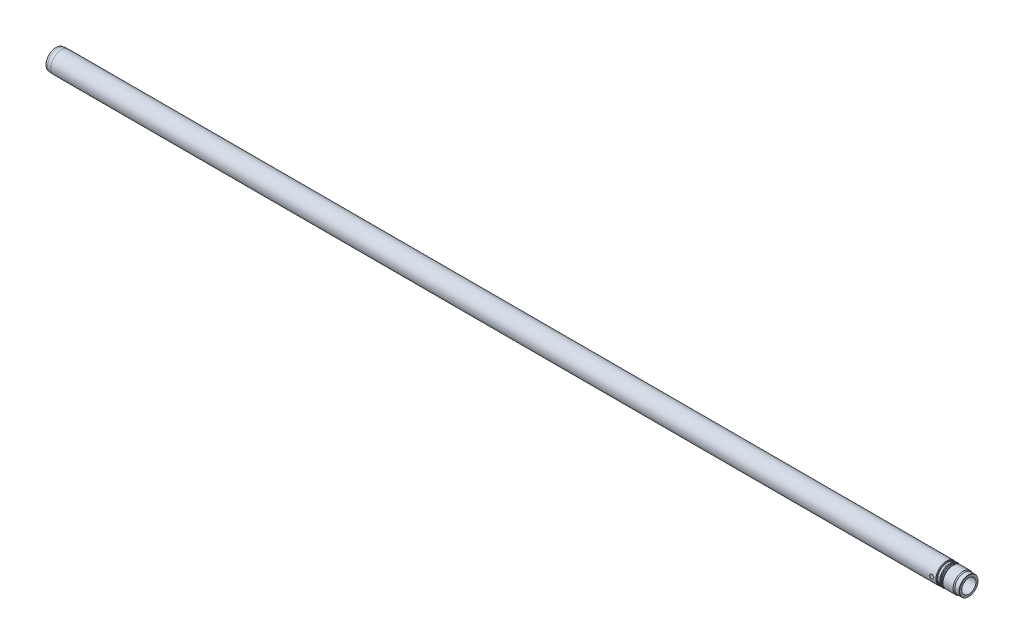
from build123d import *

# Parameters (mm, degrees)
SKETCH2_R          = 4.5
CUT_EXTRUDE1_DEPTH = 50


with BuildPart() as part:
    # Sketch1 → Base-Revolve (revolve)
    with BuildSketch(Plane.XY):
        with BuildLine():
            Line((0, 21), (0, 23.5))
            Line((0, 23.5), (0.5, 24))
            Line((0.5, 24), (5, 24))
            Line((5, 24), (5, 24.75))
            Line((5, 24.75), (13, 24.75))
            Line((13, 24.75), (13, 25))
            Line((13, 25), (2126.5, 25))
            Line((2126.5, 25), (2128, 24.133974596))
            Line((2128, 24.133974596), (2128, 23.8))
            ThreePointArc((2128, 23.8), (2128.234314575, 23.234314575), (2128.8, 23))
            Line((2128.8, 23), (2133.2, 23))
            ThreePointArc((2133.2, 23), (2133.765685425, 23.234314575), (2134, 23.8))
            Line((2134, 23.8), (2134, 24.25))
            ThreePointArc((2134, 24.25), (2134.146446609, 24.603553391), (2134.5, 24.75))
            Line((2134.5, 24.75), (2135.5, 24.75))
            Line((2135.5, 24.75), (2137, 23.883974596))
            Line((2137, 23.883974596), (2137, 23.55))
            ThreePointArc((2137, 23.55), (2137.234314575, 22.984314575), (2137.8, 22.75))
            Line((2137.8, 22.75), (2140, 22.75))
            Line((2140, 22.75), (2142.453263132, 24))
            Line((2142.453263132, 24), (2166.401923789, 24))
            Line((2166.401923789, 24), (2169, 22.5))
            Line((2169, 22.5), (2179, 22.5))
            Line((2179, 22.5), (2180, 21.922649731))
            Line((2180, 21.922649731), (2180, 17))
            Line((2180, 17), (6.92820323, 17))
            Line((6.92820323, 17), (0, 21))
        make_face()
    revolve(axis=Axis((0, 0, 0), (1, 0, 0)))

    # Sketch2 → Cut-Extrude1 (cut, symmetric)
    with BuildSketch(Plane.XY):
        with Locations((2116, 0)):
            Circle(SKETCH2_R)
    extrude(amount=CUT_EXTRUDE1_DEPTH, both=True, mode=Mode.SUBTRACT)


solid = part.part
